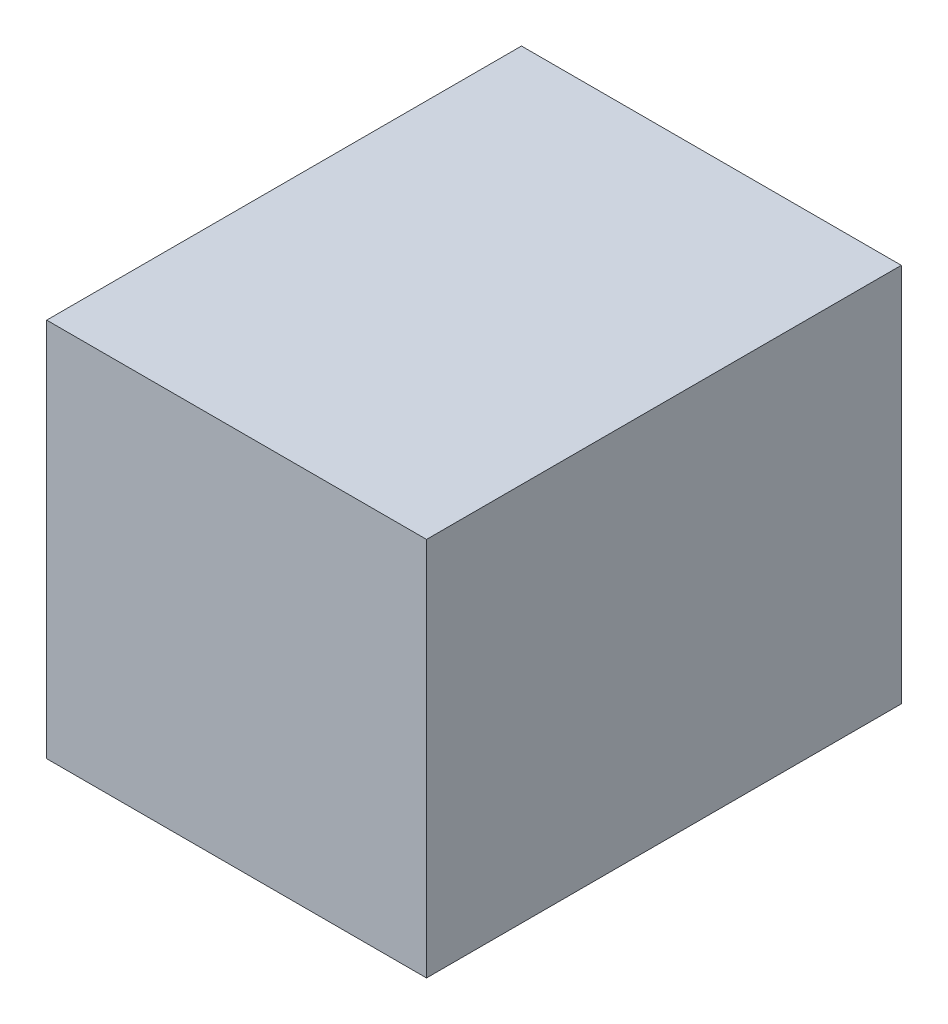
from build123d import *

# Parameters (mm, degrees)
PROFILES_W    = 0.8
PROFILES_H    = 1
PROFILE_DEPTH = 0.8


with BuildPart() as part:
    # ProfileS → Profile (new body)
    with BuildSketch(Plane(origin=(0, 0, 0), x_dir=(1, 0, 0), z_dir=(0, 1, 0))):
        Rectangle(PROFILES_W, PROFILES_H)
    extrude(amount=PROFILE_DEPTH)


solid = part.part
